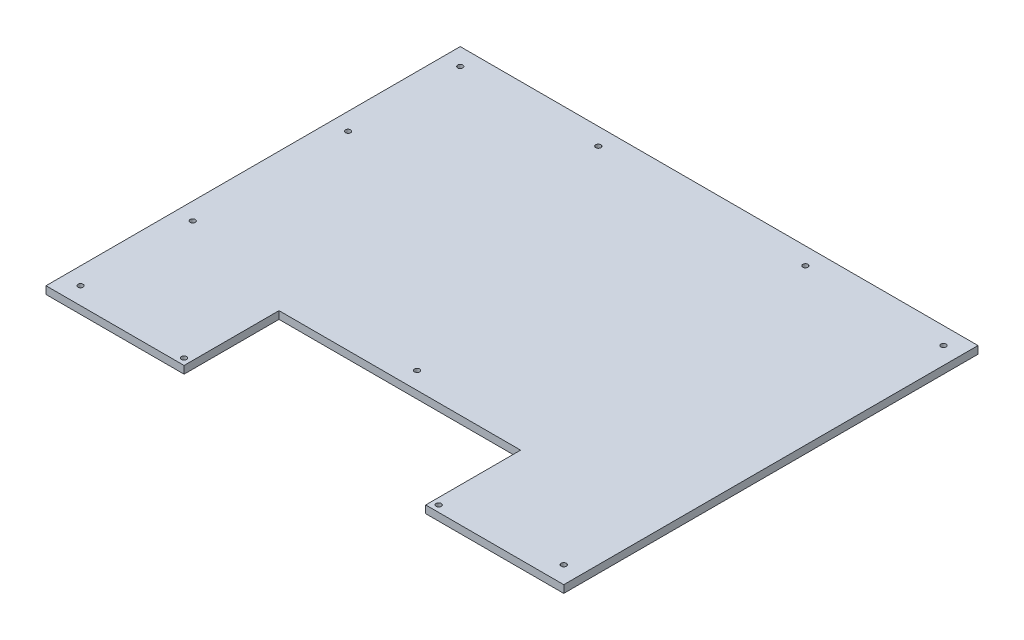
from build123d import *

# Parameters (mm, degrees)
BOSS_EXTRUDE1_DEPTH   = 5.588
F_6_CLEARANCE_HOLE1_D = 3.7973


with BuildPart() as part:
    # Sketch1 → Boss-Extrude1 (new body)
    with BuildSketch(Plane(origin=(0, 0, 0), x_dir=(1, 0, 0), z_dir=(0, 1, 0))):
        Polygon((-190.5, -152.4), (-88.9, -152.4), (-88.9, -82.55), (88.9, -82.55), (88.9, -152.4), (190.5, -152.4), (190.5, 152.4), (-190.5, 152.4), align=None)
    extrude(amount=BOSS_EXTRUDE1_DEPTH)

    # #6 Clearance Hole1 (through all)
    with Locations(Plane(origin=(-76.2, 5.588, -139.7), x_dir=(0, 0, 1), z_dir=(0, 1, 0))):
        with Locations((0, 0), (0, 152.4), (209.55, 76.2), (287.3248, -17.4752), (279.4, -101.6), (0, -101.6), (0, 254), (279.4, 254), (287.3248, 169.8752), (82.55, -101.6), (196.85, -101.6)):
            Hole(F_6_CLEARANCE_HOLE1_D / 2)


solid = part.part
